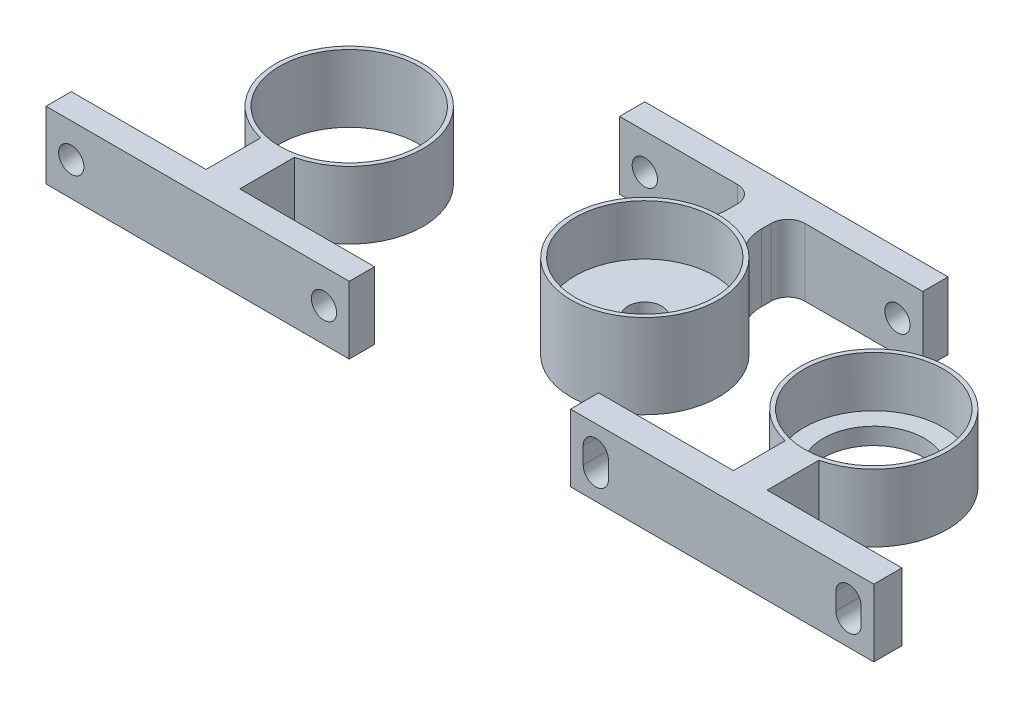
from build123d import *

# Parameters (mm, degrees)
SKETCH_1_R          = 8.75
SKETCH_1_R_2        = 8.25
EXTRUDE_2_DEPTH     = 10
SKETCH_2_R          = 8.25
SKETCH_2_R_2        = 2
EXTRUDE_3_DEPTH     = 4
EXTRUDE_4_DEPTH     = 8
SKETCH_5_W          = 3
SKETCH_5_H          = 8
EXTRUDE_5_DEPTH     = 3
SKETCH_6_W          = 3
SKETCH_6_H          = 8
EXTRUDE_6_DEPTH     = 3
SKETCH_7_R          = 1.5
CUT_EXTRUDE_1_DEPTH = 3
FILLET_1_R          = 5
FILLET_3_R          = 2
SKETCH_8_R          = 8.75
SKETCH_8_R_2        = 8.25
EXTRUDE_7_DEPTH     = 8
SKETCH_9_R          = 8.25
SKETCH_9_R_2        = 6
EXTRUDE_8_DEPTH     = 2
EXTRUDE_9_DEPTH     = 8
SKETCH_11_R         = 1.5
CUT_EXTRUDE_2_DEPTH = 8
CUT_EXTRUDE_3_DEPTH = 8
CUT_EXTRUDE_4_DEPTH = 8
SKETCH_14_R         = 8.75
SKETCH_14_R_2       = 8.25
EXTRUDE_10_DEPTH    = 8
EXTRUDE_11_DEPTH    = 8
SKETCH_16_R         = 1.5
CUT_EXTRUDE_5_DEPTH = 8


with BuildPart() as part:
    # 草图1 → 凸台-拉伸2 (new body)
    with BuildSketch(Plane(origin=(0, 0, 0), x_dir=(1, 0, 0), z_dir=(0, 1, 0))):
        Circle(SKETCH_1_R)
        Circle(SKETCH_1_R_2, mode=Mode.SUBTRACT)
    extrude(amount=EXTRUDE_2_DEPTH)

    # 草图2 → 凸台-拉伸3 (add)
    with BuildSketch(Plane(origin=(0, 0, 0), x_dir=(1, 0, 0), z_dir=(0, 1, 0))):
        Circle(SKETCH_2_R)
        Circle(SKETCH_2_R_2, mode=Mode.SUBTRACT)
    extrude(amount=EXTRUDE_3_DEPTH)

    # 草图3 → 凸台-拉伸4 (add)
    with BuildSketch(Plane(origin=(0, 0, 0), x_dir=(1, 0, 0), z_dir=(0, 1, 0))):
        Polygon((-2, 8.518362519), (2, 8.518362519), (2, 15), (15, 15), (15, 18), (2, 18), (-2, 18), (-15, 18), (-15, 15), (-2, 15), align=None)
    extrude(amount=EXTRUDE_4_DEPTH)

    # 草图5 → 凸台-拉伸5 (add)
    with BuildSketch(Plane(origin=(15, 0, 0), x_dir=(0, 0, -1), z_dir=(1, 0, 0))):
        with Locations((16.5, 4)):
            Rectangle(SKETCH_5_W, SKETCH_5_H)
    extrude(amount=EXTRUDE_5_DEPTH)

    # 草图6 → 凸台-拉伸6 (add)
    with BuildSketch(Plane.ZY.offset(15)):
        with Locations((-16.5, 4)):
            Rectangle(SKETCH_6_W, SKETCH_6_H)
    extrude(amount=EXTRUDE_6_DEPTH)

    # 草图7 → 切除-拉伸1 (cut)
    with BuildSketch(Plane(origin=(0, 0, -18), x_dir=(-1, 0, 0), z_dir=(0, 0, -1))):
        with Locations((-15, 3.754021035)):
            Circle(SKETCH_7_R)
    cut_extrude_1 = extrude(amount=-CUT_EXTRUDE_1_DEPTH, mode=Mode.SUBTRACT)

    # 镜向1: 切除-拉伸1 across plane
    add(cut_extrude_1.mirror(Plane(origin=(0, 0, 0), x_dir=(0, 0, 1), z_dir=(1, 0, 0))), mode=Mode.SUBTRACT)

    # 圆角1
    fillet_1_edges = [part.edges().sort_by_distance(p)[0] for p in [
        (-2, 4, -8.518362519),
        (2, 4, -8.518362519),
    ]]
    fillet(fillet_1_edges, radius=FILLET_1_R)

    # 圆角3
    fillet_3_edges = [part.edges().sort_by_distance(p)[0] for p in [
        (-2, 4, -15),
        (2, 4, -15),
    ]]
    fillet(fillet_3_edges, radius=FILLET_3_R)


with BuildPart() as body_2:
    # 草图8 → 凸台-拉伸7 (new body)
    with BuildSketch(Plane(origin=(0, 0, 0), x_dir=(1, 0, 0), z_dir=(0, 1, 0))):
        with Locations((27.184954533, 0)):
            Circle(SKETCH_8_R)
        with Locations((27.184954533, 0)):
            Circle(SKETCH_8_R_2, mode=Mode.SUBTRACT)
    extrude(amount=EXTRUDE_7_DEPTH)

    # 草图9 → 凸台-拉伸8 (add)
    with BuildSketch(Plane.XZ):
        with Locations((27.184954533, 0)):
            Circle(SKETCH_9_R)
        with Locations((27.184954533, 0)):
            Circle(SKETCH_9_R_2, mode=Mode.SUBTRACT)
    extrude(amount=-EXTRUDE_8_DEPTH)

    # 草图10 → 凸台-拉伸9 (add)
    with BuildSketch(Plane(origin=(0, 0, 0), x_dir=(1, 0, 0), z_dir=(0, 1, 0))):
        Polygon((27.184954533, -18), (45.184954533, -18), (45.184954533, -14.663867829), (29.184954533, -14.663867829), (29.184954533, -8.518362519), (25.184954533, -8.518362519), (25.184954533, -14.663867829), (9.184954533, -14.663867829), (9.184954533, -18), align=None)
    extrude(amount=EXTRUDE_9_DEPTH)

    # 草图11 → 切除-拉伸2 (cut)
    with BuildSketch(Plane.XY.offset(18)):
        with Locations((12.184954533, 4)):
            Circle(SKETCH_11_R)
        with Locations((42.184954533, 4)):
            Circle(SKETCH_11_R)
    extrude(amount=-CUT_EXTRUDE_2_DEPTH, mode=Mode.SUBTRACT)

    # 草图12 → 切除-拉伸3 (cut)
    with BuildSketch(Plane.XY.offset(18)):
        with BuildLine():
            Line((10.684954533, 4), (10.684954533, 5))
            ThreePointArc((10.684954533, 5), (12.184954533, 6.5), (13.684954533, 5))
            Line((13.684954533, 5), (13.684954533, 4))
            Line((13.684954533, 4), (13.684954533, 3))
            ThreePointArc((13.684954533, 3), (12.184954533, 1.5), (10.684954533, 3))
            Line((10.684954533, 3), (10.684954533, 4))
        make_face()
    extrude(amount=-CUT_EXTRUDE_3_DEPTH, mode=Mode.SUBTRACT)

    # 草图13 → 切除-拉伸4 (cut)
    with BuildSketch(Plane.XY.offset(18)):
        with BuildLine():
            Line((40.684954533, 4), (40.684954533, 5))
            ThreePointArc((40.684954533, 5), (42.184954533, 6.5), (43.684954533, 5))
            Line((43.684954533, 5), (43.684954533, 4))
            Line((43.684954533, 4), (43.684954533, 3))
            ThreePointArc((43.684954533, 3), (42.184954533, 1.5), (40.684954533, 3))
            Line((40.684954533, 3), (40.684954533, 4))
        make_face()
    extrude(amount=-CUT_EXTRUDE_4_DEPTH, mode=Mode.SUBTRACT)


with BuildPart() as body_3:
    # 草图14 → 凸台-拉伸10 (new body)
    with BuildSketch(Plane(origin=(0, 0, 0), x_dir=(1, 0, 0), z_dir=(0, 1, 0))):
        with Locations((-35.091635024, 0)):
            Circle(SKETCH_14_R)
        with Locations((-35.091635024, 0)):
            Circle(SKETCH_14_R_2, mode=Mode.SUBTRACT)
    extrude(amount=EXTRUDE_10_DEPTH)

    # 草图15 → 凸台-拉伸11 (add)
    with BuildSketch(Plane(origin=(0, 0, 0), x_dir=(1, 0, 0), z_dir=(0, 1, 0))):
        Polygon((-37.091635024, -15), (-37.091635024, -8.518362519), (-33.091635024, -8.518362519), (-33.091635024, -15), (-17.091635024, -15), (-17.091635024, -18), (-53.091635024, -18), (-53.091635024, -15), align=None)
    extrude(amount=EXTRUDE_11_DEPTH)

    # 草图16 → 切除-拉伸5 (cut)
    with BuildSketch(Plane.XY.offset(18)):
        with Locations((-50.091635024, 4)):
            Circle(SKETCH_16_R)
        with Locations((-20.091635024, 4)):
            Circle(SKETCH_16_R)
    extrude(amount=-CUT_EXTRUDE_5_DEPTH, mode=Mode.SUBTRACT)


solid = Compound([part.part, body_2.part, body_3.part])
